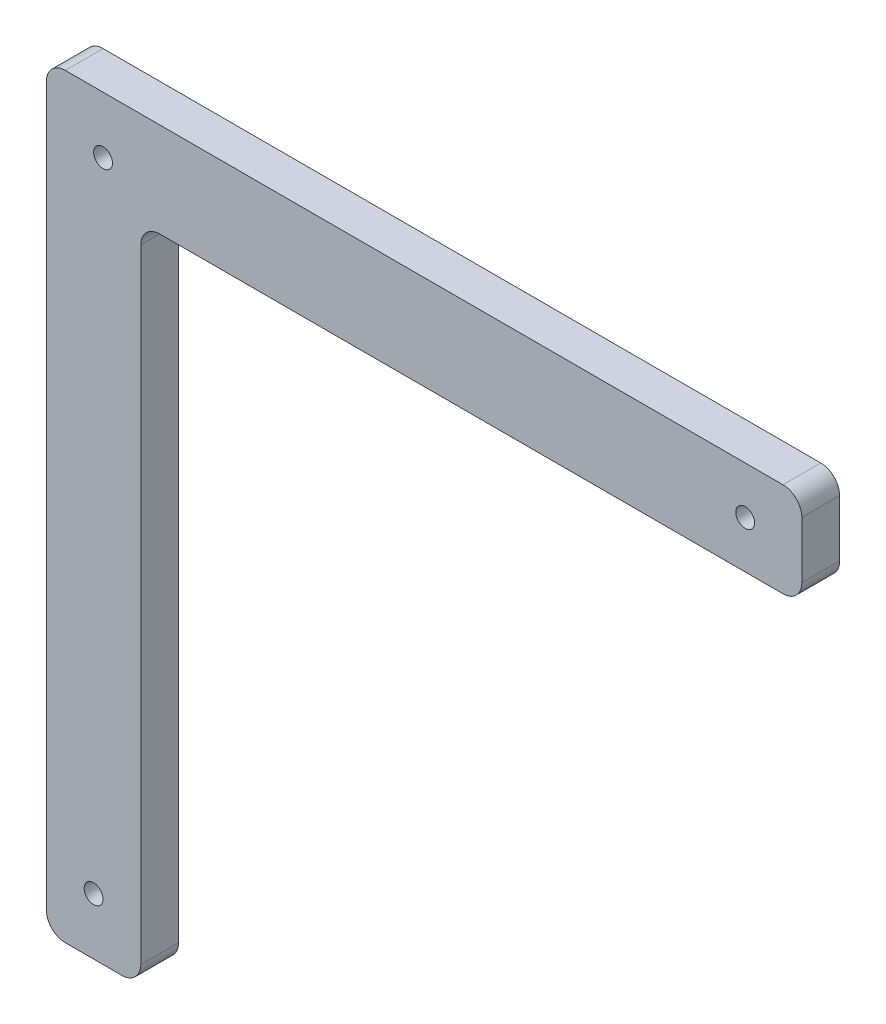
from build123d import *

# Parameters (mm, degrees)
SKETCH1_W           = 50
SKETCH1_H           = 350
SKETCH1_H_2         = 50
SKETCH1_W_2         = 350
BOSS_EXTRUDE1_DEPTH = 20
FILLET1_R           = 10
SKETCH2_R           = 5
CUT_EXTRUDE1_DEPTH  = 20


with BuildPart() as part:
    # Sketch1 → Boss-Extrude1 (new body)
    with BuildSketch(Plane.XY):
        with Locations((25, 175)):
            Rectangle(SKETCH1_W, SKETCH1_H)
        with Locations((25, 375)):
            Rectangle(SKETCH1_W, SKETCH1_H_2)
        with Locations((225, 375)):
            Rectangle(SKETCH1_W_2, SKETCH1_H_2)
    extrude(amount=BOSS_EXTRUDE1_DEPTH)

    # Fillet1
    fillet1_edges = [part.edges().sort_by_distance(p)[0] for p in [
        (50, 0, 10),
        (0, 0, 10),
        (0, 400, 10),
        (400, 400, 10),
        (400, 350, 10),
        (50, 350, 10),
    ]]
    fillet(fillet1_edges, radius=FILLET1_R)

    # Sketch2 → Cut-Extrude1 (cut)
    with BuildSketch(Plane.XY.offset(20)):
        with Locations((25, 30)):
            Circle(SKETCH2_R)
        with Locations((30, 370)):
            Circle(SKETCH2_R)
        with Locations((370, 375)):
            Circle(SKETCH2_R)
    extrude(amount=-CUT_EXTRUDE1_DEPTH, mode=Mode.SUBTRACT)


solid = part.part
